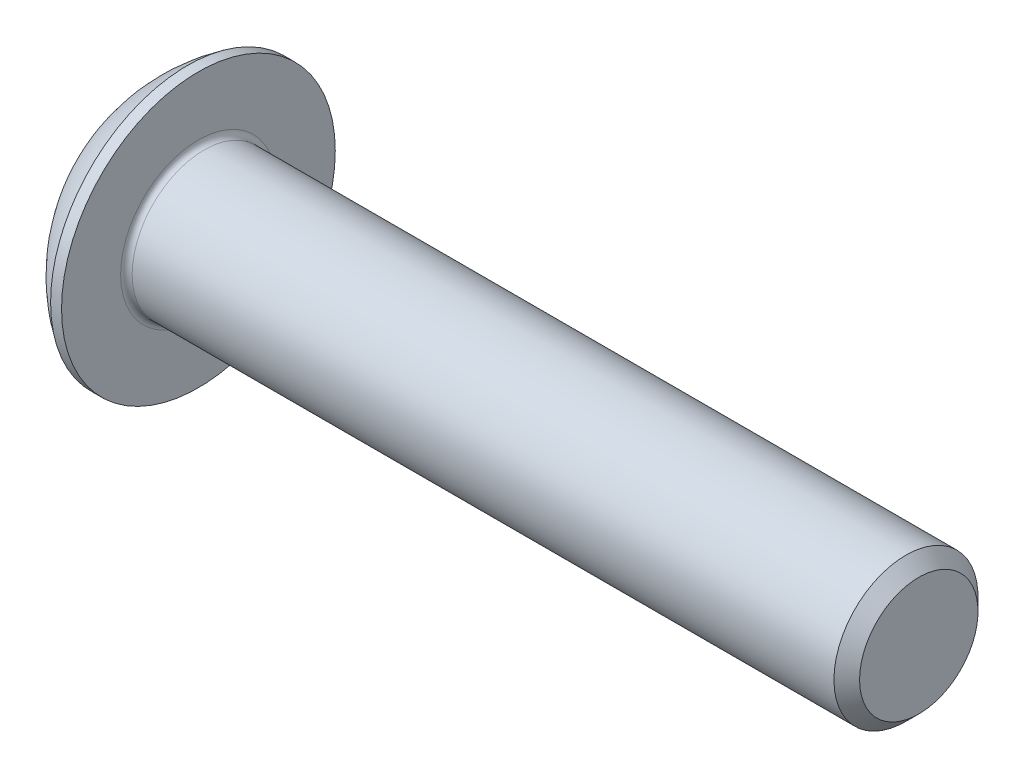
from build123d import *

# Parameters (mm, degrees)
FILLET1_R   = 0.2
HEX_2_DEPTH = 1.56


with BuildPart() as part:
    # BodySke → BaseBody (revolve)
    with BuildSketch(Plane.XY):
        with BuildLine():
            Line((27.75, 0), (27.75, 2.055))
            Line((27.75, 2.055), (27.305, 2.5))
            Line((27.305, 2.5), (2.75, 2.5))
            Line((2.75, 2.5), (2.75, 4.75))
            Line((2.75, 4.75), (2.37, 4.75))
            ThreePointArc((2.37, 4.75), (0.876917578, 3.307095591), (0, 1.425))
            Line((0, 1.425), (0, 0))
            Line((0, 0), (27.75, 0))
        make_face()
    revolve(axis=Axis((0, 0, 0), (1, 0, 0)))

    # Fillet1
    fillet1_edges = [part.edges().sort_by_distance(p)[0] for p in [
        (2.75, -2.5, 0),
    ]]
    fillet(fillet1_edges, radius=FILLET1_R)

    # Sketch2 → PreBroach (revolve, cut)
    with BuildSketch(Plane.XY):
        Polygon((0, 1.5), (1.56, 1.5), (2.426025404, 0), (0, 0), align=None)
    revolve(axis=Axis((0, 0, 0), (1, 0, 0)), mode=Mode.SUBTRACT)

    # Sketch3 → Hex 2 (cut)
    with BuildSketch(Plane(origin=(0, 0, 0), x_dir=(0, 0, -1), z_dir=(1, 0, 0))):
        Polygon((-2, -1), (-2, 1), (0, 1), (1, 1), (1, -1), (0, -1), align=None)
    extrude(amount=HEX_2_DEPTH, mode=Mode.SUBTRACT)


solid = part.part
